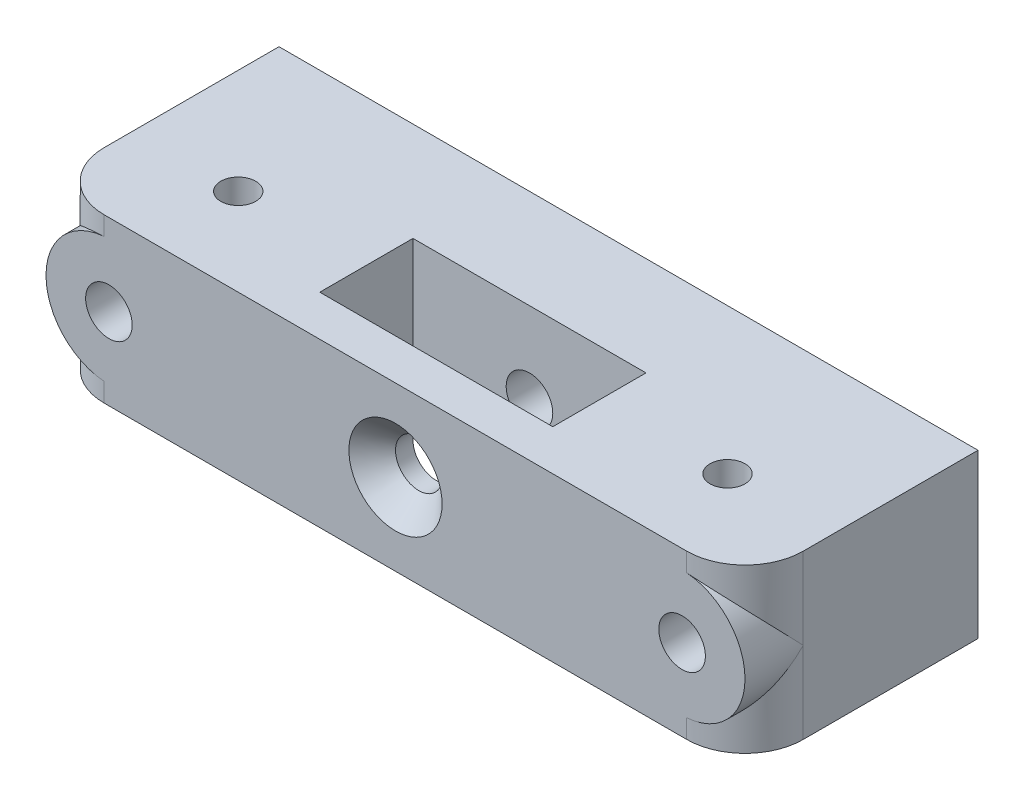
from build123d import *

# Parameters (mm, degrees)
SKETCH_1_W          = 60
SKETCH_1_H          = 14
EXTRUDE_1_DEPTH     = 20
SKETCH_2_W          = 20
SKETCH_2_H          = 8
CUT_EXTRUDE_1_DEPTH = 15
SKETCH_3_R          = 1.5
CUT_EXTRUDE_2_DEPTH = 10.5
FILLET_1_R          = 5
SKETCH_4_R          = 2
CUT_EXTRUDE_3_DEPTH = 21
CHAMFER_1_SIZE      = 2
SKETCH_5_R          = 5.4
SKETCH_5_R_2        = 2
EXTRUDE_2_DEPTH     = 5.5


with BuildPart() as part:
    # Эскиз1 → Бобышка-Вытянуть1 (new body)
    with BuildSketch(Plane.XY):
        Rectangle(SKETCH_1_W, SKETCH_1_H)
    extrude(amount=EXTRUDE_1_DEPTH)

    # Эскиз2 → Вырез-Вытянуть1 (cut, through all)
    with BuildSketch(Plane(origin=(0, -7, 0), x_dir=(-1, 0, 0), z_dir=(0, -1, 0))):
        with Locations((0, -12.5)):
            Rectangle(SKETCH_2_W, SKETCH_2_H)
    extrude(amount=-CUT_EXTRUDE_1_DEPTH, mode=Mode.SUBTRACT)

    # Эскиз3 → Вырез-Вытянуть2 (cut)
    with BuildSketch(Plane(origin=(0, 7, 0), x_dir=(1, 0, 0), z_dir=(0, 1, 0))):
        with Locations((-21, -12.5)):
            Circle(SKETCH_3_R)
        with Locations((21, -12.5)):
            Circle(SKETCH_3_R)
    extrude(amount=-CUT_EXTRUDE_2_DEPTH, mode=Mode.SUBTRACT)

    # Скругление1
    fillet_1_edges = [part.edges().sort_by_distance(p)[0] for p in [
        (30, 0, 20),
        (-30, 0, 20),
    ]]
    fillet(fillet_1_edges, radius=FILLET_1_R)

    # Эскиз4 → Вырез-Вытянуть3 (cut, through all)
    with BuildSketch(Plane.XY.offset(20)):
        with Locations((24.6, 0)):
            Circle(SKETCH_4_R)
        with Locations((-24.6, 0)):
            Circle(SKETCH_4_R)
        Circle(SKETCH_4_R)
    extrude(amount=-CUT_EXTRUDE_3_DEPTH, mode=Mode.SUBTRACT)

    # Фаска1
    chamfer_1_edges = [part.edges().sort_by_distance(p)[0] for p in [
        (-2, 0, 20),
    ]]
    chamfer(chamfer_1_edges, length=CHAMFER_1_SIZE)

    # Эскиз5 → Бобышка-Вытянуть2 (add)
    with BuildSketch(Plane.XY.offset(20)):
        with Locations((-24.6, 0)):
            Circle(SKETCH_5_R)
        with Locations((-24.6, 0)):
            Circle(SKETCH_5_R_2, mode=Mode.SUBTRACT)
        with Locations((24.6, 0)):
            Circle(SKETCH_5_R)
        with Locations((24.6, 0)):
            Circle(SKETCH_5_R_2, mode=Mode.SUBTRACT)
    extrude(amount=-EXTRUDE_2_DEPTH)


solid = part.part
